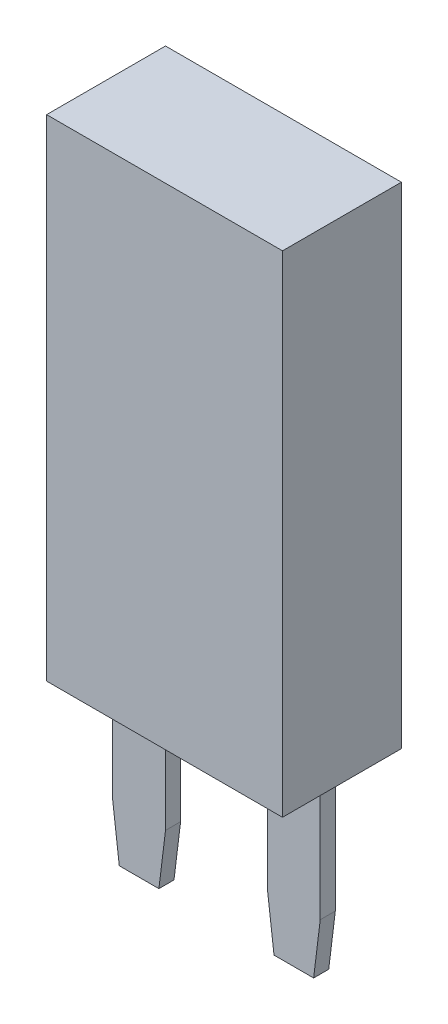
from build123d import *

# Parameters (mm, degrees)
SKETCH1_W             = 12.5
SKETCH1_H             = 26
BOSS_EXTRUDE1_DEPTH   = 3.15
SKETCH2_W             = 2.8
SKETCH2_H             = 0.8
BOSS_EXTRUDE2_DEPTH   = 9.3
CHAMFER1_SIZE         = 0.35
CHAMFER1_SIZE2        = 2.85052125
CHAMFER1_PART_2_SIZE  = 0.35
CHAMFER1_PART_2_SIZE2 = 2.85052125


with BuildPart() as part:
    # Sketch1 → Boss-Extrude1 (new body, symmetric)
    with BuildSketch(Plane.XY):
        Rectangle(SKETCH1_W, SKETCH1_H)
    extrude(amount=BOSS_EXTRUDE1_DEPTH, both=True)

    # Sketch2 → Boss-Extrude2 (add)
    with BuildSketch(Plane.XZ.offset(13)):
        with Locations((4.1, 0)):
            Rectangle(SKETCH2_W, SKETCH2_H)
        with Locations((-4.1, 0)):
            Rectangle(SKETCH2_W, SKETCH2_H)
    extrude(amount=BOSS_EXTRUDE2_DEPTH)

    # Chamfer1
    chamfer1_edges = [part.edges().sort_by_distance(p)[0] for p in [
        (-5.5, -22.3, 0),
        (-2.7, -22.3, 0),
    ]]
    chamfer1_side = [part.faces().sort_by_distance(p)[0] for p in [
        (-4.1, -22.3, 0),
    ]]
    chamfer(chamfer1_edges, length=CHAMFER1_SIZE, length2=CHAMFER1_SIZE2, reference=chamfer1_side[0])

    # Chamfer1 part 2
    chamfer1_part_2_edges = [part.edges().sort_by_distance(p)[0] for p in [
        (2.7, -22.3, 0),
        (5.5, -22.3, 0),
    ]]
    chamfer1_part_2_side = [part.faces().sort_by_distance(p)[0] for p in [
        (4.1, -22.3, 0),
    ]]
    chamfer(chamfer1_part_2_edges, length=CHAMFER1_PART_2_SIZE, length2=CHAMFER1_PART_2_SIZE2, reference=chamfer1_part_2_side[0])


solid = part.part
